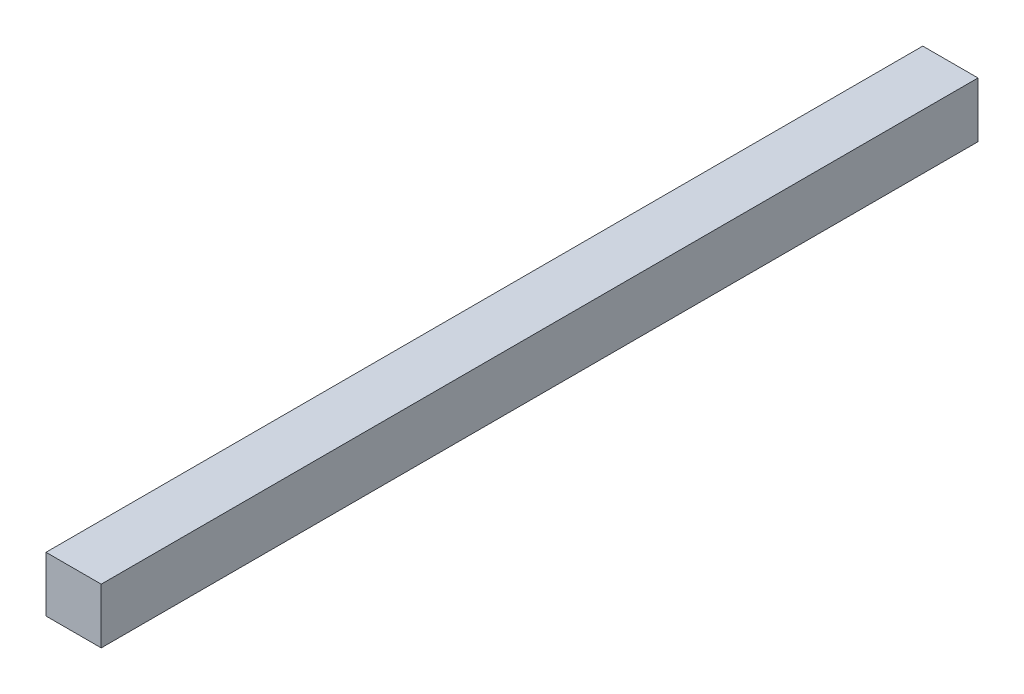
from build123d import *

# Parameters (mm, degrees)
SKETCH1_W           = 20.32
SKETCH1_H           = 20.32
BOSS_EXTRUDE1_DEPTH = 322.58


with BuildPart() as part:
    # Sketch1 → Boss-Extrude1 (new body)
    with BuildSketch(Plane.XY):
        Rectangle(SKETCH1_W, SKETCH1_H)
    extrude(amount=BOSS_EXTRUDE1_DEPTH)


solid = part.part
